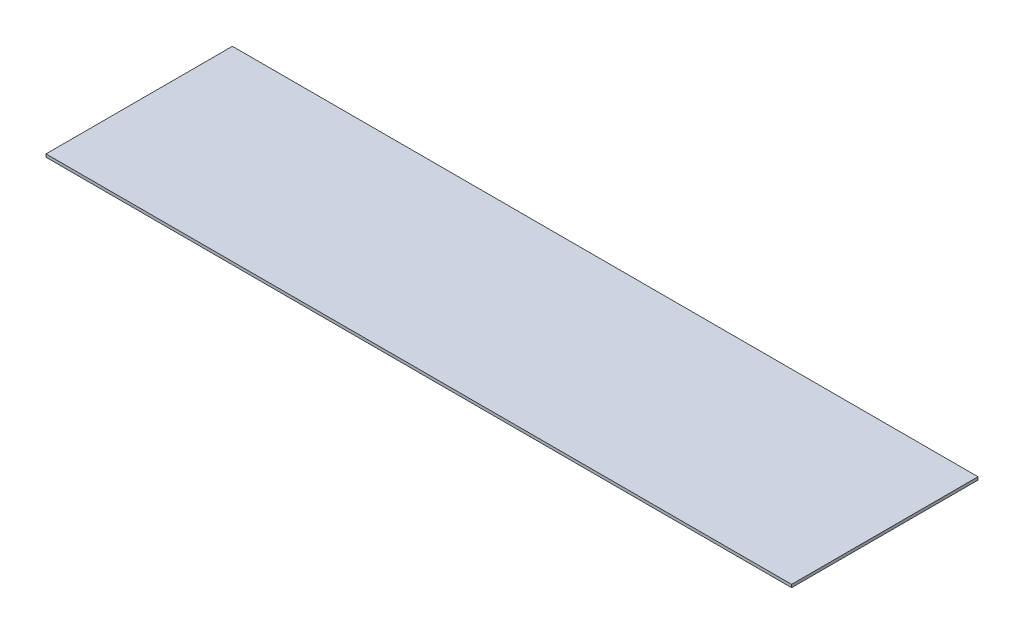
from build123d import *

# Parameters (mm, degrees)
SKETCH1_W           = 406.4
SKETCH1_H           = 101.6
BOSS_EXTRUDE1_DEPTH = 1.5875


with BuildPart() as part:
    # Sketch1 → Boss-Extrude1 (new body)
    with BuildSketch(Plane.XZ):
        with Locations((203.2, 50.8)):
            Rectangle(SKETCH1_W, SKETCH1_H)
    extrude(amount=BOSS_EXTRUDE1_DEPTH)


solid = part.part
